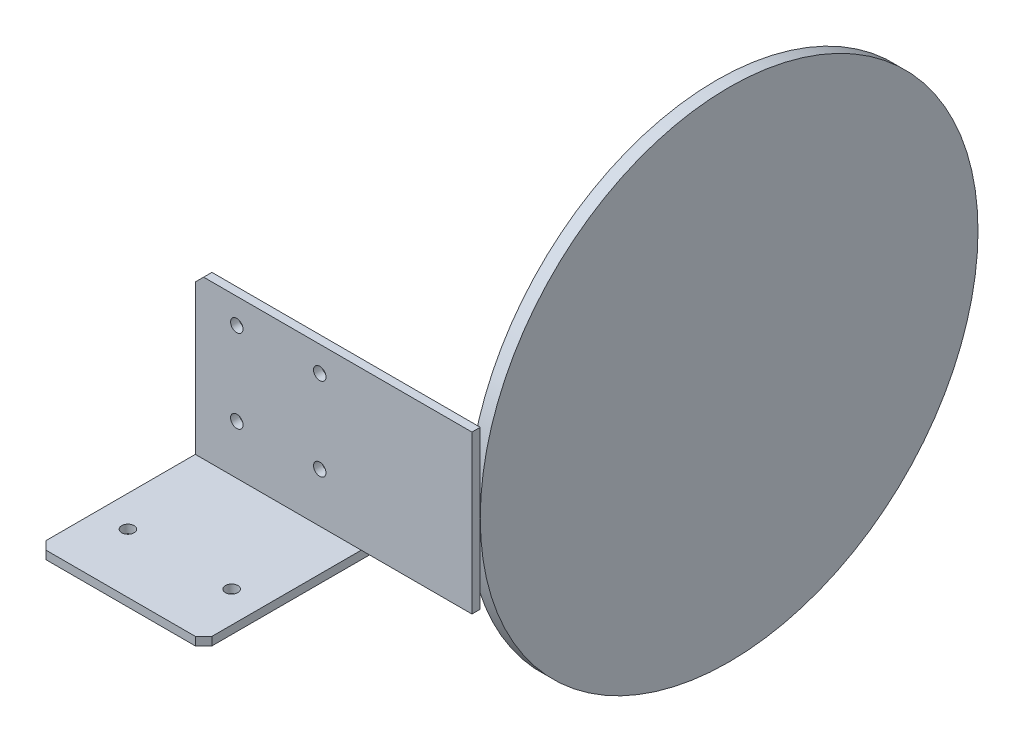
from build123d import *

# Parameters (mm, degrees)
EXTRUDE1_DEPTH           = 40
EXTRUDE2_REACH           = 42
SKETCH2_R                = 1.5
EXTRUDE3_REACH           = 42
SKETCH3_R                = 1.5
CHAMFER1_SIZE            = 2
SKETCH4_W                = 2
SKETCH4_H                = 38
BOSS_EXTRUDE1_DEPTH      = 26.69
BOSS_EXTRUDE1_DEPTH_BACK = 3
SKETCH5_R                = 60
BOSS_EXTRUDE2_DEPTH      = 3


with BuildPart() as part:
    # Sketch1 → Extrude1 (new body)
    with BuildSketch(Plane(origin=(0, 0, 0), x_dir=(0, 0, -1), z_dir=(1, 0, 0))):
        Polygon((0, 0), (0, 38), (2, 38), (2, -2), (-38, -2), (-38, 0), align=None)
    extrude(amount=EXTRUDE1_DEPTH)

    # Sketch2 → Extrude2 (cut, up to next)
    with BuildSketch(Plane(origin=(0, -2, 0), x_dir=(-1, 0, 0), z_dir=(0, -1, 0)), mode=Mode.PRIVATE) as extrude2_sk1:
        with Locations((-32.5, -23.75)):
            Circle(SKETCH2_R)
    extrude2_tool1 = extrude(extrude2_sk1.sketch, amount=-EXTRUDE2_REACH, mode=Mode.PRIVATE) & part.part
    add(extrude2_tool1.solids().sort_by_distance((32.5, -2, 23.75))[0], mode=Mode.SUBTRACT)
    # Sketch2 → Extrude2 (cut, up to next)
    with BuildSketch(Plane(origin=(0, -2, 0), x_dir=(-1, 0, 0), z_dir=(0, -1, 0)), mode=Mode.PRIVATE) as extrude2_sk2:
        with Locations((-7.5, -23.75)):
            Circle(SKETCH2_R)
    extrude2_tool2 = extrude(extrude2_sk2.sketch, amount=-EXTRUDE2_REACH, mode=Mode.PRIVATE) & part.part
    add(extrude2_tool2.solids().sort_by_distance((7.5, -2, 23.75))[0], mode=Mode.SUBTRACT)

    # Sketch3 → Extrude3 (cut, up to next)
    with BuildSketch(Plane(origin=(0, 0, -2), x_dir=(-1, 0, 0), z_dir=(0, 0, -1)), mode=Mode.PRIVATE) as extrude3_sk1:
        with Locations((-10, 31.9)):
            Circle(SKETCH3_R)
    extrude3_tool1 = extrude(extrude3_sk1.sketch, amount=-EXTRUDE3_REACH, mode=Mode.PRIVATE) & part.part
    add(extrude3_tool1.solids().sort_by_distance((10, 31.9, -2))[0], mode=Mode.SUBTRACT)
    # Sketch3 → Extrude3 (cut, up to next)
    with BuildSketch(Plane(origin=(0, 0, -2), x_dir=(-1, 0, 0), z_dir=(0, 0, -1)), mode=Mode.PRIVATE) as extrude3_sk2:
        with Locations((-30, 31.9)):
            Circle(SKETCH3_R)
    extrude3_tool2 = extrude(extrude3_sk2.sketch, amount=-EXTRUDE3_REACH, mode=Mode.PRIVATE) & part.part
    add(extrude3_tool2.solids().sort_by_distance((30, 31.9, -2))[0], mode=Mode.SUBTRACT)
    # Sketch3 → Extrude3 (cut, up to next)
    with BuildSketch(Plane(origin=(0, 0, -2), x_dir=(-1, 0, 0), z_dir=(0, 0, -1)), mode=Mode.PRIVATE) as extrude3_sk3:
        with Locations((-30, 11.9)):
            Circle(SKETCH3_R)
    extrude3_tool3 = extrude(extrude3_sk3.sketch, amount=-EXTRUDE3_REACH, mode=Mode.PRIVATE) & part.part
    add(extrude3_tool3.solids().sort_by_distance((30, 11.9, -2))[0], mode=Mode.SUBTRACT)
    # Sketch3 → Extrude3 (cut, up to next)
    with BuildSketch(Plane(origin=(0, 0, -2), x_dir=(-1, 0, 0), z_dir=(0, 0, -1)), mode=Mode.PRIVATE) as extrude3_sk4:
        with Locations((-10, 11.9)):
            Circle(SKETCH3_R)
    extrude3_tool4 = extrude(extrude3_sk4.sketch, amount=-EXTRUDE3_REACH, mode=Mode.PRIVATE) & part.part
    add(extrude3_tool4.solids().sort_by_distance((10, 11.9, -2))[0], mode=Mode.SUBTRACT)

    # Chamfer1
    chamfer1_edges = [part.edges().sort_by_distance(p)[0] for p in [
        (40, 38, -1),
        (0, 38, -1),
        (40, -1, 38),
        (0, -1, 38),
    ]]
    chamfer(chamfer1_edges, length=CHAMFER1_SIZE)

    # Sketch4 → Boss-Extrude1 (add, two sides)
    with BuildSketch(Plane(origin=(40, 0, 0), x_dir=(0, 0, -1), z_dir=(1, 0, 0))) as boss_extrude1_sk:
        with Locations((1, 19)):
            Rectangle(SKETCH4_W, SKETCH4_H)
    extrude(amount=BOSS_EXTRUDE1_DEPTH)
    extrude(boss_extrude1_sk.sketch, amount=-BOSS_EXTRUDE1_DEPTH_BACK)


with BuildPart() as body_2:
    # Sketch5 → Boss-Extrude2 (new body)
    with BuildSketch(Plane(origin=(66.69, 0, 0), x_dir=(0, 0, -1), z_dir=(1, 0, 0))):
        with Locations((62, 19)):
            Circle(SKETCH5_R)
    extrude(amount=-BOSS_EXTRUDE2_DEPTH)


solid = Compound([part.part, body_2.part])
